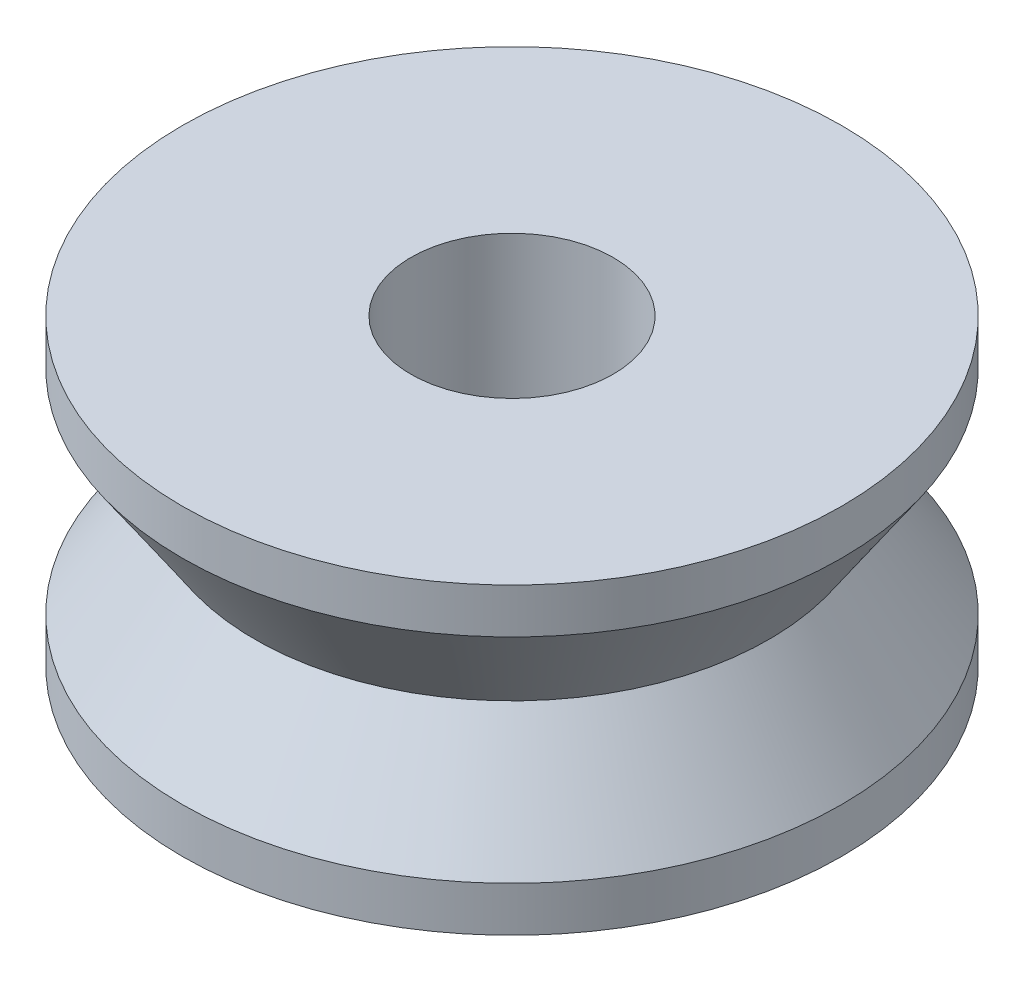
from build123d import *


with BuildPart() as part:
    # Sketch1 → Revolve2 (revolve)
    with BuildSketch(Plane.XY):
        Polygon((-6.5151, -2.1082), (-6.5151, -2.9972), (-2, -2.9972), (-2, 2.9972), (-6.5151, 2.9972), (-6.5151, 2.1082), (-5.08, 0), align=None)
    revolve(axis=Axis((0, 0, 0), (0, 1, 0)))


solid = part.part
